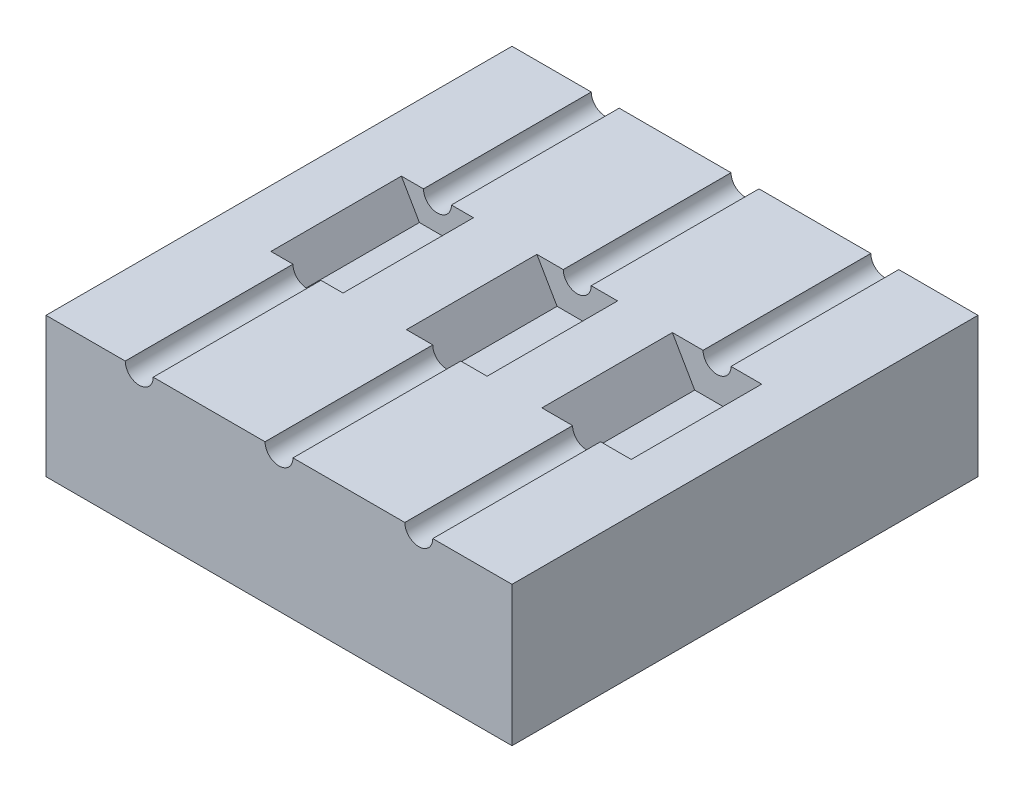
from build123d import *

# Parameters (mm, degrees)
SKETCH2_W                 = 25
SKETCH2_H                 = 25
BOSS_EXTRUDE1_DEPTH       = 7.5
CUT_HEX_DEPTH             = 3.5
CUT_HEX_DEPTH_BACK        = 3.5
SKETCH4_R                 = 0.75
CUT_CABLE_EXIT_DEPTH      = 17
CUT_CABLE_EXIT_DEPTH_BACK = 10


with BuildPart() as part:
    # Sketch2 → Boss-Extrude1 (new body)
    with BuildSketch(Plane(origin=(0, 0, 0), x_dir=(1, 0, 0), z_dir=(0, 1, 0))):
        with Locations((12.5, 12.5)):
            Rectangle(SKETCH2_W, SKETCH2_H)
    extrude(amount=BOSS_EXTRUDE1_DEPTH)

    # Sketch3 → Cut-Hex (cut, two sides)
    with BuildSketch(Plane.XY.offset(-12.5)) as cut_hex_sk:
        Polygon((4.032938299, 5.825), (5.967061701, 5.825), (6.934123402, 7.5), (3.065876598, 7.5), align=None)
        Polygon((11.417468245, 5.625), (13.582531755, 5.625), (14.665063509, 7.5), (10.334936491, 7.5), align=None)
        Polygon((18.801998191, 5.425), (21.198001809, 5.425), (22.396003617, 7.5), (17.603996383, 7.5), align=None)
    extrude(amount=CUT_HEX_DEPTH, mode=Mode.SUBTRACT)
    extrude(cut_hex_sk.sketch, amount=-CUT_HEX_DEPTH_BACK, mode=Mode.SUBTRACT)

    # Sketch4 → Cut-Cable Exit (cut, two sides)
    with BuildSketch(Plane(origin=(0, 0, -9), x_dir=(-1, 0, 0), z_dir=(0, 0, -1))) as cut_cable_exit_sk:
        with Locations((-12.5, 7.5)):
            Circle(SKETCH4_R)
        with Locations((-20, 7.5)):
            Circle(SKETCH4_R)
        with Locations((-5, 7.5)):
            Circle(SKETCH4_R)
    extrude(amount=CUT_CABLE_EXIT_DEPTH, mode=Mode.SUBTRACT)
    extrude(cut_cable_exit_sk.sketch, amount=-CUT_CABLE_EXIT_DEPTH_BACK, mode=Mode.SUBTRACT)


solid = part.part
